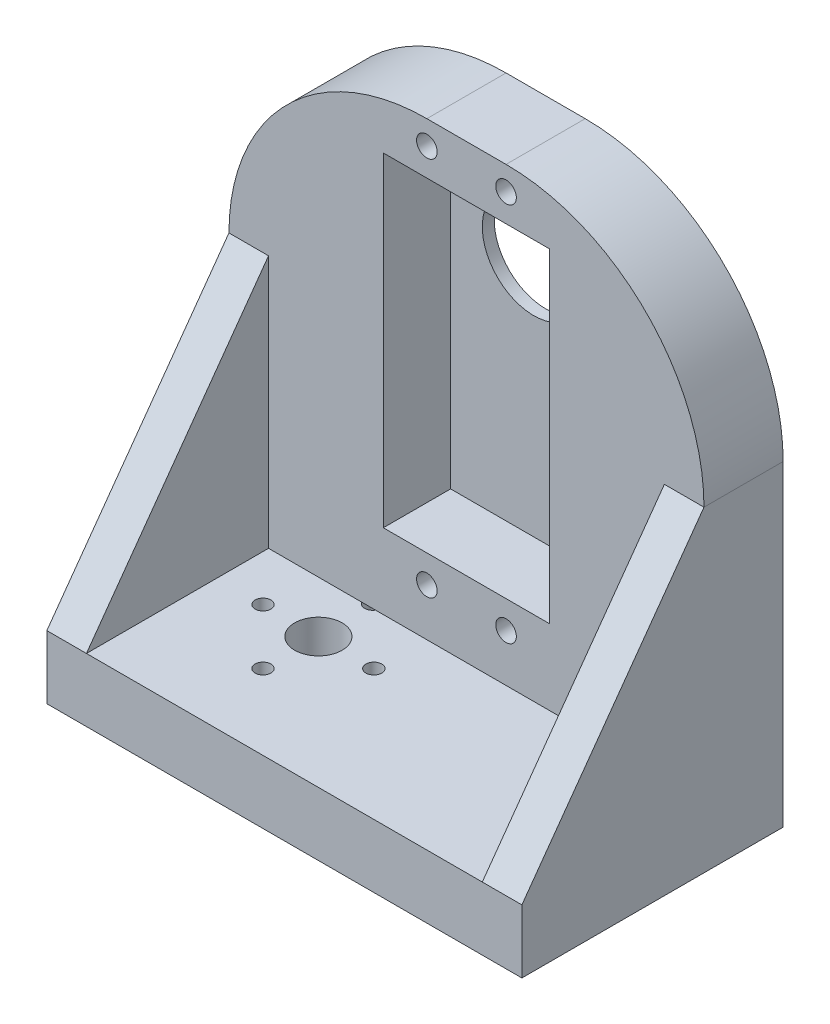
from build123d import *

# Parameters (mm, degrees)
SKETCH2_W           = 60
SKETCH2_H           = 33
BOSS_EXTRUDE1_DEPTH = 65
SKETCH3_W           = 23
SKETCH3_H           = 57
CUT_EXTRUDE1_DEPTH  = 60
SKETCH4_W           = 21
SKETCH4_H           = 41
CUT_EXTRUDE2_DEPTH  = 8.5
SKETCH4_3_R         = 1.3
CUT_EXTRUDE3_DEPTH  = 11
SKETCH6_R           = 3
SKETCH6_R_2         = 1
CUT_EXTRUDE4_DEPTH  = 66
FILLET2_R           = 25
FILLET4_R           = 25
BOSS_EXTRUDE2_DEPTH = 5
SKETCH9_R           = 6.5
CUT_EXTRUDE5_DEPTH  = 2.5
SKETCH10_R          = 10.5
CUT_EXTRUDE6_DEPTH  = 2.3
SKETCH12_R          = 1
CUT_EXTRUDE7_DEPTH  = 5.7


with BuildPart() as part:
    # Sketch2 → Boss-Extrude1 (new body)
    with BuildSketch(Plane(origin=(0, 0, 0), x_dir=(1, 0, 0), z_dir=(0, 1, 0))):
        Rectangle(SKETCH2_W, SKETCH2_H)
    extrude(amount=BOSS_EXTRUDE1_DEPTH)

    # Sketch3 → Cut-Extrude1 (cut)
    with BuildSketch(Plane.ZY.offset(30)):
        with Locations((5, 36.5)):
            Rectangle(SKETCH3_W, SKETCH3_H)
    extrude(amount=-CUT_EXTRUDE1_DEPTH, mode=Mode.SUBTRACT)

    # Sketch4 → Cut-Extrude2 (cut)
    with BuildSketch(Plane.XY.offset(-6.5)):
        with Locations((0, 38)):
            Rectangle(SKETCH4_W, SKETCH4_H)
    extrude(amount=-CUT_EXTRUDE2_DEPTH, mode=Mode.SUBTRACT)

    # Sketch4_3 → Cut-Extrude3 (cut, through all)
    with BuildSketch(Plane.XY.offset(-6.5)):
        with Locations((5, 14)):
            Circle(SKETCH4_3_R)
        with Locations((-5, 62)):
            Circle(SKETCH4_3_R)
        with Locations((5, 62)):
            Circle(SKETCH4_3_R)
        with Locations((-5, 14)):
            Circle(SKETCH4_3_R)
    extrude(amount=-CUT_EXTRUDE3_DEPTH, mode=Mode.SUBTRACT)

    # Sketch6 → Cut-Extrude4 (cut, through all)
    with BuildSketch(Plane.XZ):
        with Locations((-12.2, 0)):
            Circle(SKETCH6_R)
        with Locations((-19.2, 0)):
            Circle(SKETCH6_R_2)
        with Locations((-5.2, 0)):
            Circle(SKETCH6_R_2)
        with Locations((-12.2, 7)):
            Circle(SKETCH6_R_2)
    extrude(amount=-CUT_EXTRUDE4_DEPTH, mode=Mode.SUBTRACT)

    # Fillet2
    fillet2_edges = [part.edges().sort_by_distance(p)[0] for p in [
        (-30, 65, -11.5),
    ]]
    fillet(fillet2_edges, radius=FILLET2_R)

    # Fillet4
    fillet4_edges = [part.edges().sort_by_distance(p)[0] for p in [
        (30, 65, -11.5),
    ]]
    fillet(fillet4_edges, radius=FILLET4_R)

    # Sketch8 → Boss-Extrude2 (add)
    with BuildSketch(Plane.ZY.offset(30)):
        Polygon((-6.5, 40), (16.5, 8), (-6.5, 8), align=None)
    boss_extrude2 = extrude(amount=-BOSS_EXTRUDE2_DEPTH)

    # Mirror1: Boss-Extrude2 across plane
    add(boss_extrude2.mirror(Plane(origin=(0, 0, 0), x_dir=(0, 0, 1), z_dir=(1, 0, 0))))

    # Sketch9 → Cut-Extrude5 (cut, through all)
    with BuildSketch(Plane.XY.offset(-15)):
        with Locations((0, 48.2)):
            Circle(SKETCH9_R)
    extrude(amount=-CUT_EXTRUDE5_DEPTH, mode=Mode.SUBTRACT)

    # Sketch10 → Cut-Extrude6 (cut)
    with BuildSketch(Plane.XZ):
        with Locations((-12.2, 0)):
            Circle(SKETCH10_R)
    extrude(amount=-CUT_EXTRUDE6_DEPTH, mode=Mode.SUBTRACT)

    # Sketch12 → Cut-Extrude7 (cut)
    with BuildSketch(Plane.XZ.offset(-2.3)):
        with Locations((-12.35085129, -7)):
            Circle(SKETCH12_R)
    extrude(amount=-CUT_EXTRUDE7_DEPTH, mode=Mode.SUBTRACT)


solid = part.part
